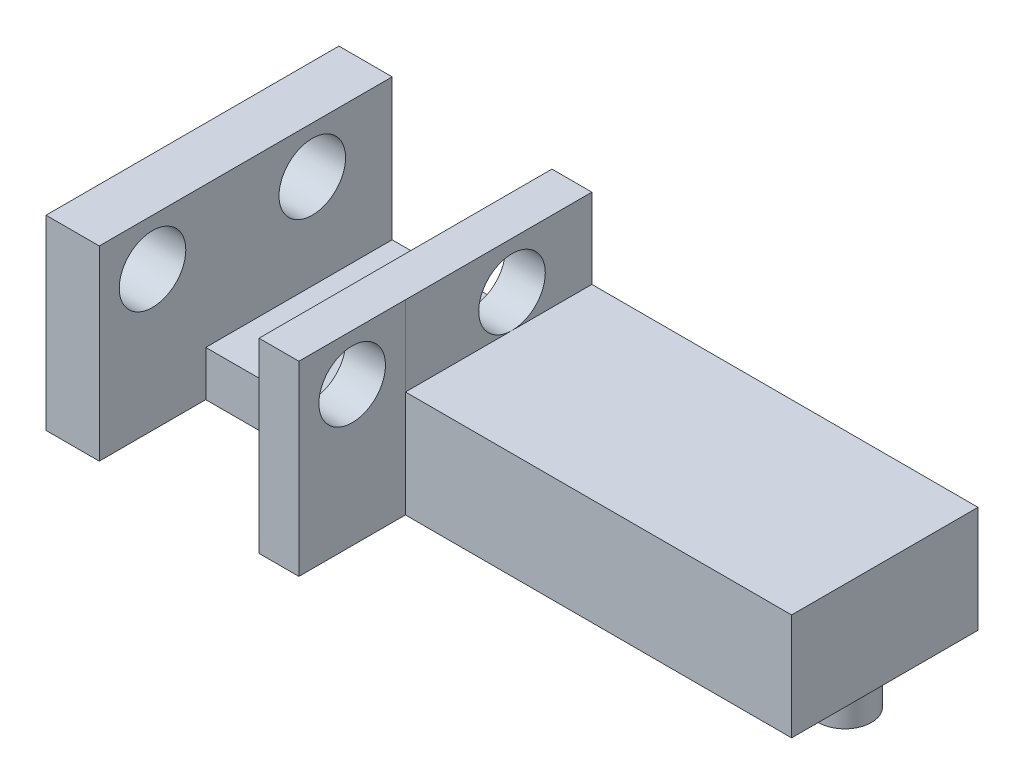
from build123d import *

# Parameters (mm, degrees)
BOSS_EXTRUDE1_DEPTH = 3
SKETCH3_W           = 24
SKETCH3_H           = 4
BOSS_EXTRUDE2_DEPTH = 4
SKETCH6_W           = 24
SKETCH6_H           = 4
BOSS_EXTRUDE4_DEPTH = 3
CUT_EXTRUDE1_DEPTH  = 2.3
SKETCH9_W           = 2
SKETCH9_H           = 7
SKETCH9_W_2         = 1.5
BOSS_EXTRUDE5_DEPTH = 3
SKETCH11_W          = 2
SKETCH11_H          = 7
SKETCH11_W_2        = 1.497470588
BOSS_EXTRUDE6_DEPTH = 4
SKETCH10_R          = 1.25
CUT_EXTRUDE2_DEPTH  = 10.5


with BuildPart() as part:
    # Sketch1 → Boss-Extrude1 (new body)
    with BuildSketch(Plane(origin=(0, 0, 0), x_dir=(1, 0, 0), z_dir=(0, 1, 0))):
        with BuildLine():
            ThreePointArc((-17, 2), (-18.5, 3.5), (-20, 2))
            Line((-20, 2), (-17, 2))
        make_face()
        with BuildLine():
            Line((-17, 2), (-20, 2))
            ThreePointArc((-20, 2), (-18.5, 0.5), (-17, 2))
        make_face()
        with BuildLine():
            Line((-23, 3), (-23, 2))
            Line((-23, 2), (-23, 1))
            ThreePointArc((-23, 1), (-22.292893219, 1.292893219), (-22, 2))
            ThreePointArc((-22, 2), (-22.292893219, 2.707106781), (-23, 3))
        make_face()
        with BuildLine():
            Line((-23, 1), (-23, 2))
            Line((-23, 2), (-24, 2))
            ThreePointArc((-24, 2), (-23.707106781, 1.292893219), (-23, 1))
        make_face()
        with BuildLine():
            Line((-24, 2), (-23, 2))
            Line((-23, 2), (-23, 3))
            ThreePointArc((-23, 3), (-23.707106781, 2.707106781), (-24, 2))
        make_face()
        with BuildLine():
            ThreePointArc((-13, 2), (-14, 3), (-15, 2))
            Line((-15, 2), (-13, 2))
        make_face()
        with BuildLine():
            Line((-13, 2), (-15, 2))
            ThreePointArc((-15, 2), (-14, 1), (-13, 2))
        make_face()
        with BuildLine():
            ThreePointArc((-3, 2), (-4, 3), (-5, 2))
            Line((-5, 2), (-3, 2))
        make_face()
        with BuildLine():
            Line((-3, 2), (-5, 2))
            ThreePointArc((-5, 2), (-4, 1), (-3, 2))
        make_face()
    extrude(amount=-BOSS_EXTRUDE1_DEPTH)

    # Sketch3 → Boss-Extrude2 (add)
    with BuildSketch(Plane(origin=(0, 0, 0), x_dir=(1, 0, 0), z_dir=(0, 1, 0))):
        with Locations((-13, 2)):
            Rectangle(SKETCH3_W, SKETCH3_H)
    extrude(amount=BOSS_EXTRUDE2_DEPTH)

    # Sketch6 → Boss-Extrude4 (add)
    with BuildSketch(Plane.XY):
        with Locations((-13, 2)):
            Rectangle(SKETCH6_W, SKETCH6_H)
    extrude(amount=BOSS_EXTRUDE4_DEPTH)

    # Sketch7 → Cut-Extrude1 (cut)
    with BuildSketch(Plane(origin=(0, 4, 0), x_dir=(1, 0, 0), z_dir=(0, 1, 0))):
        Polygon((-23, 0.5), (-23, -3), (-17, -3), (-17, 4), (-23, 4), align=None)
    extrude(amount=-CUT_EXTRUDE1_DEPTH, mode=Mode.SUBTRACT)

    # Sketch9 → Boss-Extrude5 (add)
    with BuildSketch(Plane(origin=(0, 4, 0), x_dir=(1, 0, 0), z_dir=(0, 1, 0))):
        with Locations((-24, 0.5)):
            Rectangle(SKETCH9_W, SKETCH9_H)
        with Locations((-16.25, 0.5)):
            Rectangle(SKETCH9_W_2, SKETCH9_H)
    extrude(amount=BOSS_EXTRUDE5_DEPTH)

    # Sketch11 → Boss-Extrude6 (add)
    with BuildSketch(Plane.XY.offset(3)):
        with Locations((-24, 3.5)):
            Rectangle(SKETCH11_W, SKETCH11_H)
        with Locations((-16.251264706, 3.5)):
            Rectangle(SKETCH11_W_2, SKETCH11_H)
    extrude(amount=BOSS_EXTRUDE6_DEPTH)

    # Sketch10 → Cut-Extrude2 (cut, through all)
    with BuildSketch(Plane(origin=(-15.5, 0, 0), x_dir=(0, 0, -1), z_dir=(1, 0, 0))):
        with Locations((1, 5.25)):
            Circle(SKETCH10_R)
        with Locations((-5, 5.25)):
            Circle(SKETCH10_R)
    extrude(amount=-CUT_EXTRUDE2_DEPTH, mode=Mode.SUBTRACT)


solid = part.part
